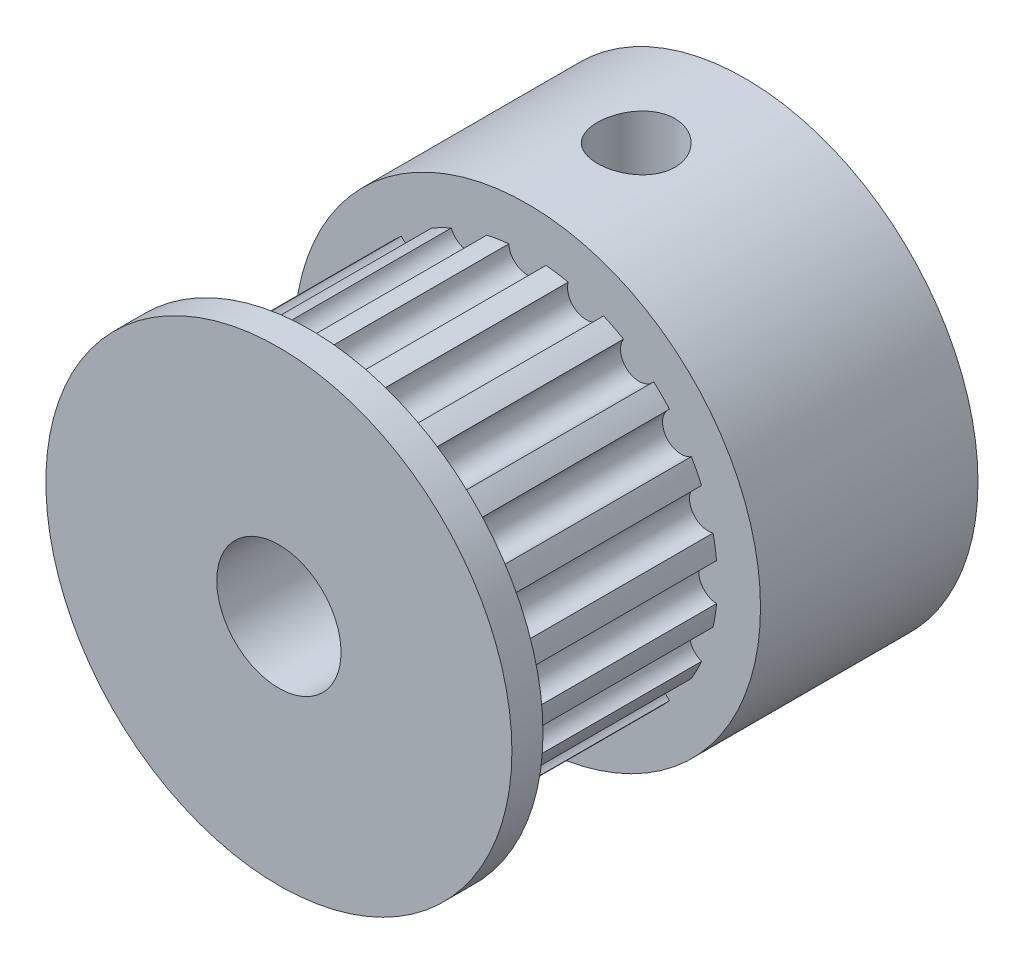
from build123d import *

# Parameters (mm, degrees)
SKETCH_1_R               = 7.5
EXTRUDE_1_DEPTH          = 3.5
SKETCH_2_R               = 6.115
EXTRUDE_2_DEPTH          = 7
CUT_EXTRUDE_3_DEPTH      = 7
SKETCH_3_R               = 7.5
EXTRUDE_3_DEPTH          = 1
SKETCH_6_R               = 2
CUT_EXTRUDE_2_DEPTH      = 16
PATTERN_CIRCULAR_2_COUNT = 20
SKETCH_13_W              = 1.25
SKETCH_13_H              = 7.5
PATTERN_CIRCULAR_4_COUNT = 2
PATTERN_CIRCULAR_4_ANGLE = 90


with BuildPart() as part:
    # 草圖1 → 填料-伸長1 (new body, symmetric)
    with BuildSketch(Plane.XY):
        Circle(SKETCH_1_R)
    extrude(amount=EXTRUDE_1_DEPTH, both=True)

    # 草圖2 → 填料-伸長2 (add)
    with BuildSketch(Plane.XY.offset(3.5)):
        Circle(SKETCH_2_R)
    extrude(amount=EXTRUDE_2_DEPTH)

    # 草圖7 → 除料-伸長3 (cut)
    with BuildSketch(Plane.XY.offset(10.5)):
        with BuildLine():
            ThreePointArc((-0.599277509, 6.085564186), (0, 5.515), (0.599277509, 6.085564186))
            ThreePointArc((0.599277509, 6.085564186), (0, 6.115), (-0.599277509, 6.085564186))
        make_face()
    cut_extrude_3 = extrude(amount=-CUT_EXTRUDE_3_DEPTH, mode=Mode.SUBTRACT)

    # 草圖3 → 填料-伸長3 (add)
    with BuildSketch(Plane.XY.offset(10.5)):
        Circle(SKETCH_3_R)
    extrude(amount=EXTRUDE_3_DEPTH)

    # 草圖6 → 除料-伸長2 (cut, through all)
    with BuildSketch(Plane(origin=(0, 0, -3.5), x_dir=(-1, 0, 0), z_dir=(0, 0, -1))):
        Circle(SKETCH_6_R)
    extrude(amount=-CUT_EXTRUDE_2_DEPTH, mode=Mode.SUBTRACT)

    # 環狀複製排列2: 除料-伸長3 ×20 about axis
    pattern_circular_2_axis = Axis((0, 0, 0), (0, 0, 1))
    for i in range(1, PATTERN_CIRCULAR_2_COUNT):
        add(cut_extrude_3.rotate(pattern_circular_2_axis, i * 360 / PATTERN_CIRCULAR_2_COUNT), mode=Mode.SUBTRACT)

    # 草圖13 → M3x0.5 螺紋孔3 (revolve, cut)
    with BuildSketch(Plane(origin=(0, 0, 0), x_dir=(0, 0, -1), z_dir=(1, 0, 0))):
        with Locations((0.625, 3.75)):
            Rectangle(SKETCH_13_W, SKETCH_13_H)
    m3x0_5_3 = revolve(axis=Axis((0, -6.35, 0), (0, 1, 0)), mode=Mode.SUBTRACT)

    # 環狀複製排列4: M3x0.5 螺紋孔3 ×2 about axis
    pattern_circular_4_axis = Axis((0, 0, 3.5), (0, 0, 1))
    for i in range(1, PATTERN_CIRCULAR_4_COUNT):
        add(m3x0_5_3.rotate(pattern_circular_4_axis, i * PATTERN_CIRCULAR_4_ANGLE / (PATTERN_CIRCULAR_4_COUNT - 1)), mode=Mode.SUBTRACT)


solid = part.part
